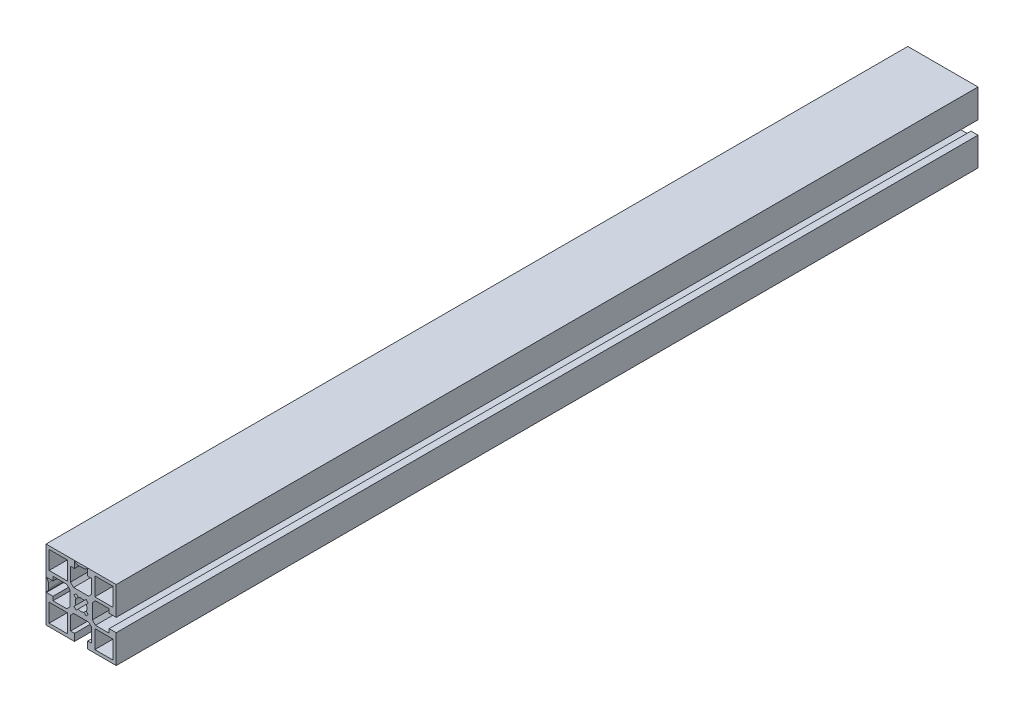
from build123d import *

# Parameters (mm, degrees)
SKETCH1_W           = 11.699975178
SKETCH1_H           = 11.699996949
SKETCH1_W_2         = 11.699990436
SKETCH1_H_2         = 11.699981689
SKETCH1_W_3         = 11.699990437
SKETCH1_H_3         = 11.699975177
SKETCH1_W_4         = 11.699981689
SKETCH1_H_4         = 11.699990436
BOSS_EXTRUDE1_DEPTH = 552.45


with BuildPart() as part:
    # Sketch1 → Boss-Extrude1 (new body)
    with BuildSketch(Plane.XY):
        Polygon((22.500515052, 22.499297556), (-22.499484399, 22.499298105), (-22.499484948, -22.500701346), (-4.249491942, -22.500701568), (-4.249491942, -22.200733242), (-4.24949208, -18.000719999), (-6.799479919, -18.000719999), (-6.799480207, -9.200732353), (-4.799480391, -7.200732362), (4.800525817, -7.200732047), (6.8005258, -9.200731855), (6.800526088, -18.000720263), (4.250507877, -18.000720263), (4.250508015, -22.200733153), (4.250508015, -22.500701672), (22.500514502, -22.500701895), (22.500514725, -4.250714302), (22.200520351, -4.250714302), (18.000507108, -4.25071444), (18.000507108, -6.800702279), (9.200519462, -6.800702567), (7.200519471, -4.800702751), (7.200519156, 4.799303458), (9.200518964, 6.79930344), (18.000507424, 6.799303729), (18.000507424, 4.249285514), (22.200520261, 4.249285652), (22.500514829, 4.249285652), align=None)
        with BuildLine():
            Line((-4.249491247, 17.999291576), (-4.249490956, 22.199304807))
            Line((-4.249490956, 22.199304807), (-3.949472548, 22.199304807))
            Line((-3.949472548, 22.199304807), (-3.481695222, 21.73152644))
            ThreePointArc((-3.481695222, 21.73152644), (-2.670636178, 21.189593132), (-1.713926324, 20.999291428))
            Line((-1.713926324, 20.999291428), (1.714975167, 20.999291428))
            ThreePointArc((1.714975167, 20.999291428), (2.671722509, 21.189608628), (3.482801459, 21.731583767))
            Line((3.482801459, 21.731583767), (3.950490798, 22.199304487))
            Line((3.950490798, 22.199304487), (4.250509108, 22.199304487))
            Line((4.250509108, 22.199304487), (4.250508817, 17.999291575))
            Line((4.250508817, 17.999291575), (6.800527063, 17.999291575))
            Line((6.800527063, 17.999291575), (6.800526453, 9.199302988))
            Line((6.800526453, 9.199302988), (4.800526064, 7.199302969))
            Line((4.800526064, 7.199302969), (-4.799479817, 7.199303635))
            Line((-4.799479817, 7.199303635), (-6.799479854, 9.199304042))
            Line((-6.799479854, 9.199304042), (-6.799479244, 17.999291576))
            Line((-6.799479244, 17.999291576), (-4.249491247, 17.999291576))
        make_face(mode=Mode.SUBTRACT)
        with BuildLine():
            Line((-17.99949762, -4.250714253), (-22.199510799, -4.250714391))
            Line((-22.199510799, -4.250714391), (-22.199510799, -3.950696126))
            Line((-22.199510799, -3.950696126), (-21.731790056, -3.48300681))
            ThreePointArc((-21.731790056, -3.48300681), (-21.189814855, -2.671927844), (-20.999497617, -1.71518046))
            Line((-20.999497617, -1.71518046), (-20.999497617, 1.713721031))
            ThreePointArc((-20.999497617, 1.713721031), (-21.189799286, 2.670430863), (-21.731732544, 3.481489907))
            Line((-21.731732544, 3.481489907), (-22.199510888, 3.949267256))
            Line((-22.199510888, 3.949267256), (-22.199510888, 4.249285566))
            Line((-22.199510888, 4.249285566), (-17.999497356, 4.249285704))
            Line((-17.999497356, 4.249285704), (-17.999497356, 6.79927354))
            Line((-17.999497356, 6.79927354), (-9.199509947, 6.799273828))
            Line((-9.199509947, 6.799273828), (-7.199509956, 4.799274012))
            Line((-7.199509956, 4.799274012), (-7.199509641, -4.800732197))
            Line((-7.199509641, -4.800732197), (-9.199509449, -6.800732179))
            Line((-9.199509449, -6.800732179), (-17.99949762, -6.800732468))
            Line((-17.99949762, -6.800732468), (-17.99949762, -4.250714253))
        make_face(mode=Mode.SUBTRACT)
        with Locations((-14.649542346, -14.650709384)):
            Rectangle(SKETCH1_W, SKETCH1_H, mode=Mode.SUBTRACT)
        with Locations((14.65050626, -14.650767962)):
            Rectangle(SKETCH1_W_2, SKETCH1_H_2, mode=Mode.SUBTRACT)
        with BuildLine():
            Line((-3.181457266, -4.596908447), (-4.595670829, -3.182694885))
            Line((-4.595670829, -3.182694885), (-3.26221457, -1.849238626))
            ThreePointArc((-3.26221457, -1.849238626), (-3.749476751, -0.00071437), (-3.26221457, 1.847809887))
            Line((-3.26221457, 1.847809887), (-4.595670829, 3.181266146))
            Line((-4.595670829, 3.181266146), (-3.181457266, 4.595479708))
            Line((-3.181457266, 4.595479708), (-1.848001007, 3.262023449))
            ThreePointArc((-1.848001007, 3.262023449), (0.000523249, 3.74928563), (1.849047505, 3.262023449))
            Line((1.849047505, 3.262023449), (3.182503764, 4.595479708))
            Line((3.182503764, 4.595479708), (4.596717327, 3.181266146))
            Line((4.596717327, 3.181266146), (3.263261068, 1.847809887))
            ThreePointArc((3.263261068, 1.847809887), (3.750523249, -0.00071437), (3.263261068, -1.849238626))
            Line((3.263261068, -1.849238626), (4.596717327, -3.182694885))
            Line((4.596717327, -3.182694885), (3.182503764, -4.596908447))
            Line((3.182503764, -4.596908447), (1.849047505, -3.263452188))
            ThreePointArc((1.849047505, -3.263452188), (0.000523249, -3.75071437), (-1.848001007, -3.263452188))
            Line((-1.848001007, -3.263452188), (-3.181457266, -4.596908447))
        make_face(mode=Mode.SUBTRACT)
        with Locations((-14.64949028, 14.649335967)):
            Rectangle(SKETCH1_W_3, SKETCH1_H_3, mode=Mode.SUBTRACT)
        with Locations((14.650561583, 14.6492839)):
            Rectangle(SKETCH1_W_4, SKETCH1_H_4, mode=Mode.SUBTRACT)
    extrude(amount=BOSS_EXTRUDE1_DEPTH)


solid = part.part
